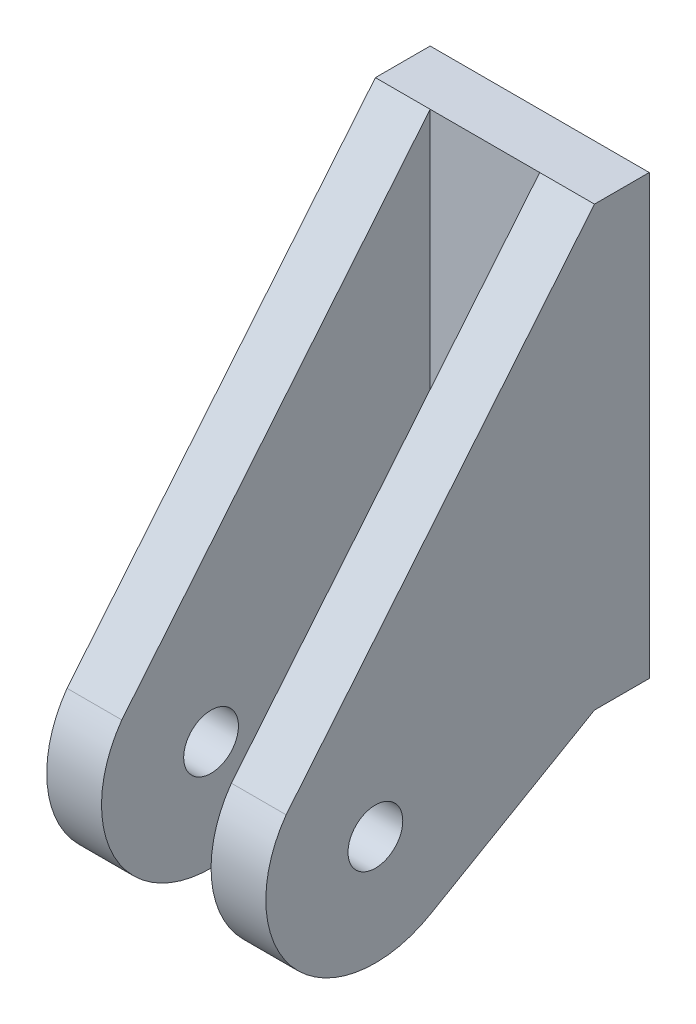
from build123d import *

# Parameters (mm, degrees)
SKETCH1_W           = 25.4
SKETCH1_H           = 50.8
BOSS_EXTRUDE1_DEPTH = 6.35
SKETCH2_R           = 3.175
BOSS_EXTRUDE2_DEPTH = 6.35
SKETCH3_R           = 3.175
BOSS_EXTRUDE3_DEPTH = 6.35


with BuildPart() as part:
    # Sketch1 → Boss-Extrude1 (new body)
    with BuildSketch(Plane.XY):
        with Locations((12.7, 25.4)):
            Rectangle(SKETCH1_W, SKETCH1_H)
    extrude(amount=BOSS_EXTRUDE1_DEPTH)

    # Sketch2 → Boss-Extrude2 (add)
    with BuildSketch(Plane(origin=(25.4, 0, 0), x_dir=(0, 0, -1), z_dir=(1, 0, 0))):
        with BuildLine():
            Line((-6.35, 0), (-25.4, -10.998522628))
            ThreePointArc((-25.4, -10.998522628), (-41.146035344, -8.544268244), (-42.097436971, 7.363460336))
            Line((-42.097436971, 7.363460336), (-6.35, 50.8))
            Line((-6.35, 50.8), (-6.35, 0))
        make_face()
        with Locations((-31.75, 0)):
            Circle(SKETCH2_R, mode=Mode.SUBTRACT)
    extrude(amount=-BOSS_EXTRUDE2_DEPTH)

    # Sketch3 → Boss-Extrude3 (add)
    with BuildSketch(Plane.ZY):
        with BuildLine():
            Line((6.35, 0), (25.4, -10.998522628))
            ThreePointArc((25.4, -10.998522628), (41.146035344, -8.544268244), (42.097436971, 7.363460336))
            Line((42.097436971, 7.363460336), (6.35, 50.8))
            Line((6.35, 50.8), (6.35, 0))
        make_face()
        with Locations((31.75, 0)):
            Circle(SKETCH3_R, mode=Mode.SUBTRACT)
    extrude(amount=-BOSS_EXTRUDE3_DEPTH)


solid = part.part
